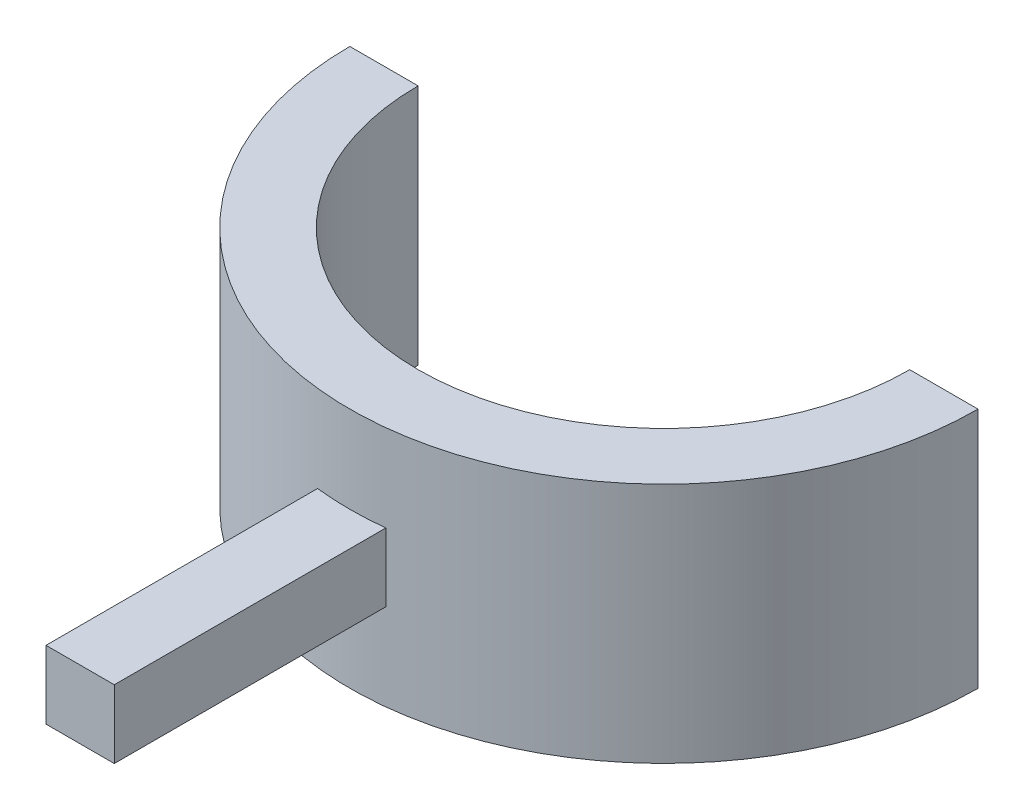
from build123d import *

# Parameters (mm, degrees)
BOSS_EXTRUDE1_DEPTH             = 17.71
SKETCH2_W                       = 5
SKETCH2_H                       = 5
BOSS_EXTRUDE2_DEPTH             = 19.75
BOSS_EXTRUDE2_DIRECTION_2_REACH = 25


with BuildPart() as part:
    # Sketch1 → Boss-Extrude1 (new body)
    with BuildSketch(Plane(origin=(0, 0, 0), x_dir=(1, 0, 0), z_dir=(0, 1, 0))):
        with BuildLine():
            Line((23, 23), (18, 23))
            ThreePointArc((18, 23), (0, 5), (-18, 23))
            Line((-18, 23), (-23, 23))
            ThreePointArc((-23, 23), (0, 0), (23, 23))
        make_face()
    extrude(amount=BOSS_EXTRUDE1_DEPTH)


with BuildPart() as body_2:
    # Sketch2 → Boss-Extrude2 (new body)
    with BuildSketch(Plane.XY):
        with Locations((0, 8.855)):
            Rectangle(SKETCH2_W, SKETCH2_H)
    extrude(amount=BOSS_EXTRUDE2_DEPTH)


    # Sketch2 → Boss-Extrude2 direction 2 (add, up to next)
    with BuildSketch(Plane.XY, mode=Mode.PRIVATE) as boss_extrude2_direction_2_sk1:
        with Locations((0, 8.855)):
            Rectangle(SKETCH2_W, SKETCH2_H)
    boss_extrude2_direction_2_tool1 = extrude(boss_extrude2_direction_2_sk1.sketch, amount=-BOSS_EXTRUDE2_DIRECTION_2_REACH, mode=Mode.PRIVATE) - part.part
    add(boss_extrude2_direction_2_tool1.solids().sort_by_distance((0, 8.855, 0))[0])
    add(boss_extrude2_direction_2_tool1.solids().sort_by_distance((0, 8.855, 0))[1])


solid = Compound([part.part, body_2.part])
